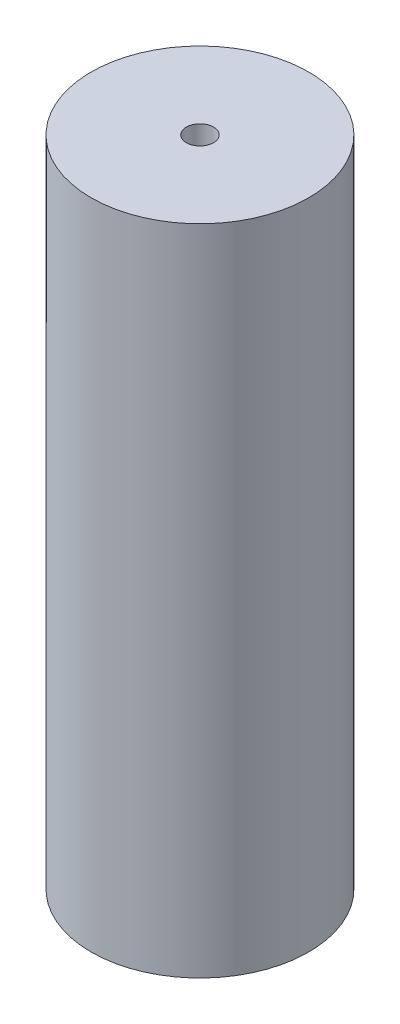
from build123d import *

# Parameters (mm, degrees)
SKETCH1_R           = 25.4
BOSS_EXTRUDE1_DEPTH = 152.4
SKETCH4_R           = 3.175
CUT_EXTRUDE1_DEPTH  = 152.4


with BuildPart() as part:
    # Sketch1 → Boss-Extrude1 (new body)
    with BuildSketch(Plane(origin=(0, 0, 0), x_dir=(1, 0, 0), z_dir=(0, 1, 0))):
        Circle(SKETCH1_R)
    extrude(amount=BOSS_EXTRUDE1_DEPTH)

    # Sketch4 → Cut-Extrude1 (cut)
    with BuildSketch(Plane.XZ):
        Circle(SKETCH4_R)
    extrude(amount=-CUT_EXTRUDE1_DEPTH, mode=Mode.SUBTRACT)


solid = part.part
